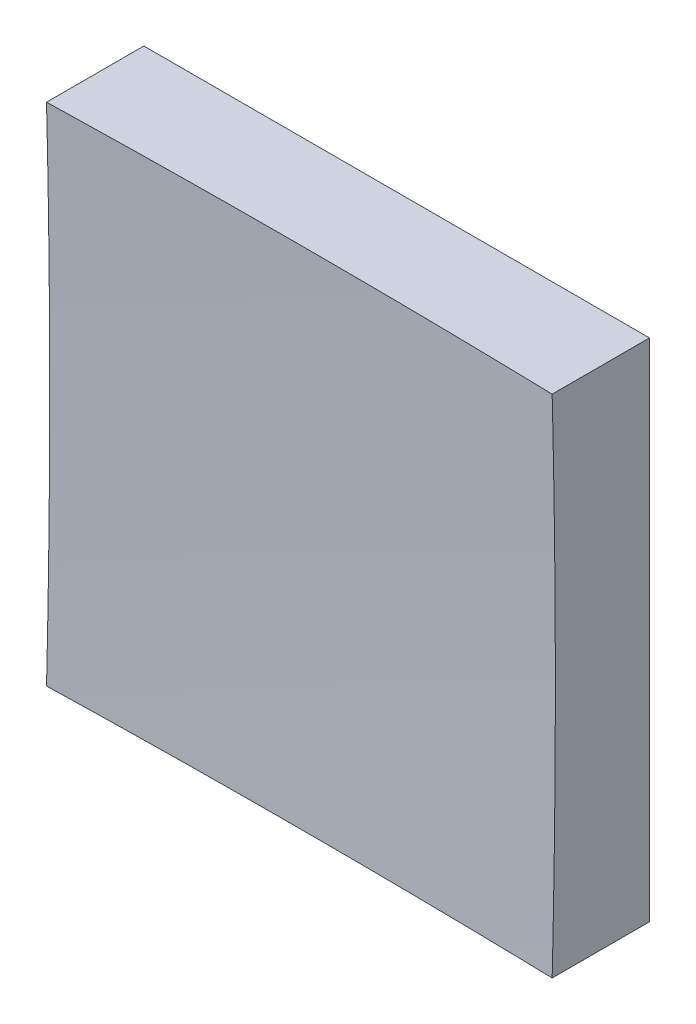
from build123d import *

# Parameters (mm, degrees)
SKETCH_1_W      = 50
SKETCH_1_H      = 50
EXTRUDE_1_DEPTH = 50


with BuildPart() as part:
    # 草图1 → 凸台-拉伸1 (new body)
    with BuildSketch(Plane.XY):
        Rectangle(SKETCH_1_W, SKETCH_1_H)
    extrude(amount=EXTRUDE_1_DEPTH)

    # 草图2 → 切除-旋转2 (revolve, cut)
    with BuildSketch(Plane(origin=(0, 0, 0), x_dir=(1, 0, 0), z_dir=(0, 1, 0))):
        with BuildLine():
            Line((974.845461813, -786.118135366), (0, -786.118135366))
            Line((0, -786.118135366), (0, -9))
            ThreePointArc((0, -9), (623.345063094, -227.053114133), (974.845461813, -786.118135366))
        make_face()
    revolve(axis=Axis((0, 0, 786.118135366), (0, 0, -1)), mode=Mode.SUBTRACT)


solid = part.part
